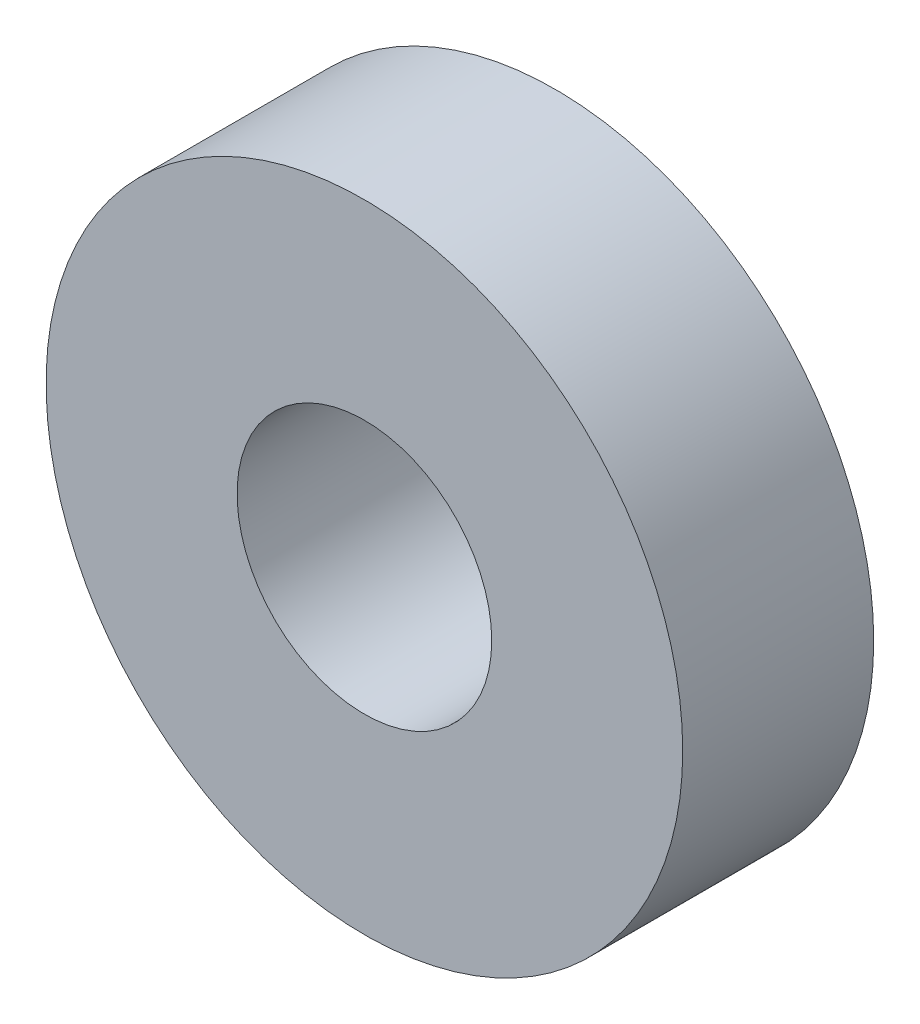
from build123d import *

# Parameters (mm, degrees)
SKETCH1_R           = 10
SKETCH1_R_2         = 4
BOSS_EXTRUDE1_DEPTH = 6


with BuildPart() as part:
    # Sketch1 → Boss-Extrude1 (new body)
    with BuildSketch(Plane.XY):
        Circle(SKETCH1_R)
        Circle(SKETCH1_R_2, mode=Mode.SUBTRACT)
    extrude(amount=BOSS_EXTRUDE1_DEPTH)


solid = part.part
